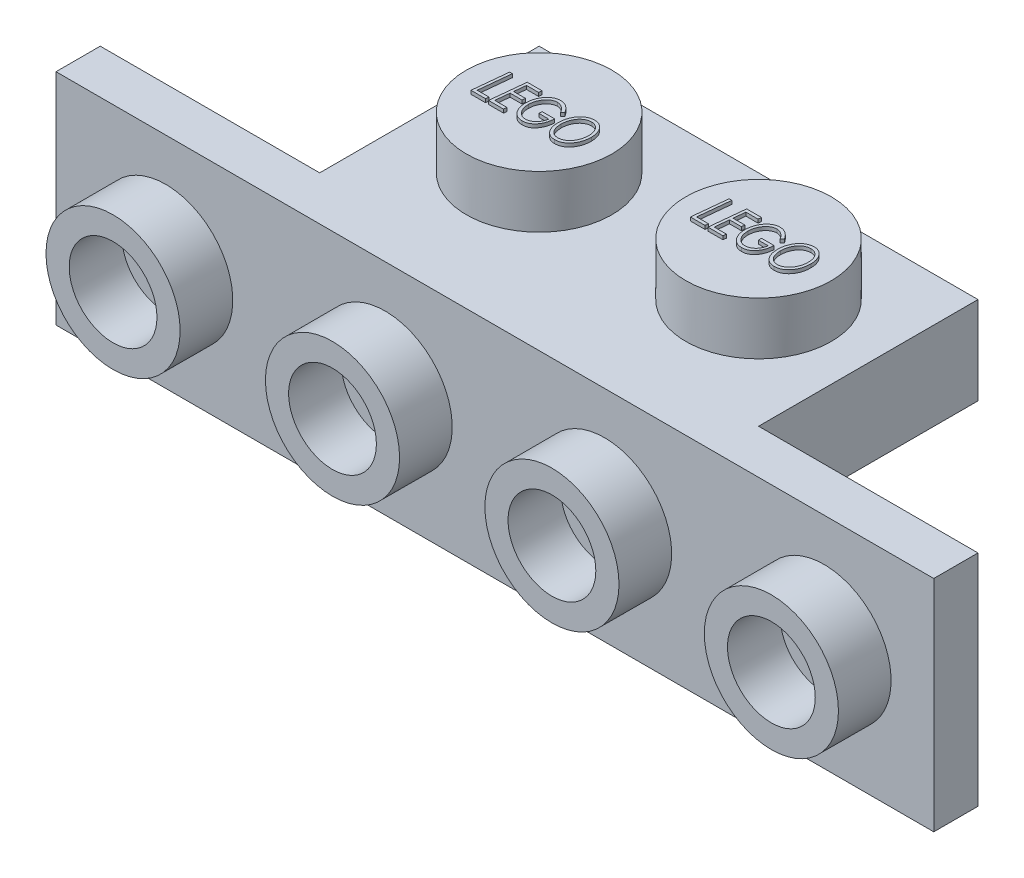
from build123d import *

# Parameters (mm, degrees)
SKETCH2_W           = 15.875
SKETCH2_H           = 7.9375
BOSS_EXTRUDE3_DEPTH = 3.175
SKETCH3_R           = 2.630752939
BOSS_EXTRUDE4_DEPTH = 1.905
LPATTERN1_COUNT     = 2
LPATTERN1_PITCH     = 7.9375
SHELL1_T            = -1.524
BOSS_EXTRUDE5_DEPTH = 0.127
LPATTERN2_COUNT     = 2
LPATTERN2_PITCH     = 7.9375
SKETCH5_R           = 1.4986
SKETCH5_R_2         = 0.635
BOSS_EXTRUDE6_DEPTH = 1.651
SKETCH6_W           = 31.75
SKETCH6_H           = 7.9375
BOSS_EXTRUDE7_DEPTH = 1.6002
SKETCH7_R           = 2.4257
SKETCH7_R_2         = 1.5875
BOSS_EXTRUDE8_DEPTH = 1.905
LPATTERN3_COUNT     = 4
LPATTERN3_PITCH     = 7.9375


with BuildPart() as part:
    # Sketch2 → Boss-Extrude3 (new body)
    with BuildSketch(Plane(origin=(0, 0, 0), x_dir=(1, 0, 0), z_dir=(0, 1, 0))):
        with Locations((-9.795613381, 4.754641089)):
            Rectangle(SKETCH2_W, SKETCH2_H)
    extrude(amount=BOSS_EXTRUDE3_DEPTH)

    # Sketch3 → Boss-Extrude4 (add)
    with BuildSketch(Plane(origin=(0, 3.175, 0), x_dir=(1, 0, 0), z_dir=(0, 1, 0))):
        with Locations((-13.764363381, 4.754641089)):
            Circle(SKETCH3_R)
    boss_extrude4 = extrude(amount=BOSS_EXTRUDE4_DEPTH)

    # LPattern1: Boss-Extrude4 ×2
    with Locations(*[(i * LPATTERN1_PITCH, 0, 0) for i in range(1, LPATTERN1_COUNT)]):
        add(boss_extrude4)

    # Shell1
    shell1_openings = [part.faces().sort_by_distance(p)[0] for p in [
        (-9.795613381, 0, -4.754641089),
    ]]
    offset(amount=SHELL1_T, openings=shell1_openings, kind=Kind.INTERSECTION)

    # Sketch4 → Boss-Extrude5 (add)
    with BuildSketch(Plane(origin=(0, 5.08, 0), x_dir=(1, 0, 0), z_dir=(0, 1, 0))):
        Polygon((-15.421955913, 5.34660841), (-15.323500384, 5.34660841), (-15.441290849, 4.190582769), (-15.01414141, 4.190582769), (-15.02533532, 4.07660841), (-15.551449102, 4.07660841), align=None)
        Polygon((-14.248885, 5.34660841), (-14.262877387, 5.232634051), (-14.699694294, 5.232634051), (-14.742943493, 4.809300718), (-14.314013205, 4.809300718), (-14.326733557, 4.695326359), (-14.754646217, 4.695326359), (-14.806036442, 4.190582769), (-14.362859359, 4.190582769), (-14.374307676, 4.07660841), (-14.916449102, 4.07660841), (-14.786701506, 5.34660841), align=None)
        with BuildLine():
            Line((-13.157987564, 5.079226599), (-13.23685375, 5.004685333))
            add(Edge.make_bspline(
                [(-13.23685375, 5.004685333), (-13.243036349, 5.014919943), (-13.255215537, 5.03508124), (-13.274843903, 5.0639219), (-13.295404966, 5.090766309), (-13.316668722, 5.115943823), (-13.338681843, 5.139287343), (-13.361588027, 5.160749301), (-13.385450265, 5.180091456), (-13.409701872, 5.197942406), (-13.434658284, 5.213660022), (-13.459747782, 5.227481566), (-13.485177989, 5.238904833), (-13.510565197, 5.248734726), (-13.536282118, 5.256136896), (-13.562187777, 5.261089256), (-13.588089761, 5.264689825), (-13.605477312, 5.265029123), (-13.614139407, 5.265198154)],
                knots=[0, 0, 0, 0, 3.5867e-05, 7.0655e-05, 0.000104594, 0.000137266, 0.00016948, 0.0002008, 0.000231355, 0.000261581, 0.000291084, 0.000319773, 0.000347439, 0.000374655, 0.000401388, 0.000427582, 0.000453742, 0.000479711, 0.000479711, 0.000479711, 0.000479711], degree=3))
            add(Edge.make_bspline(
                [(-13.614139407, 5.265198154), (-13.623817018, 5.264942089), (-13.643246281, 5.264428001), (-13.672242613, 5.260605848), (-13.70083591, 5.253771652), (-13.729278127, 5.244988175), (-13.757272205, 5.233098144), (-13.785048709, 5.218900423), (-13.812373825, 5.20184576), (-13.839460855, 5.182752056), (-13.865426178, 5.16117013), (-13.890266569, 5.13792049), (-13.91359838, 5.112994152), (-13.935710508, 5.086452282), (-13.955872189, 5.057845897), (-13.975112242, 5.027830316), (-13.992587445, 4.995991744), (-14.008566347, 4.962671117), (-14.023015409, 4.928317995), (-14.035508966, 4.893155428), (-14.045942052, 4.857372561), (-14.054589121, 4.820944025), (-14.06149942, 4.783854091), (-14.066312673, 4.746142046), (-14.069143076, 4.707836031), (-14.069568079, 4.682101861), (-14.069782435, 4.669122433)],
                knots=[0, 0, 0, 0, 2.903e-05, 5.8283e-05, 8.7534e-05, 0.000117144, 0.000147477, 0.000178653, 0.000210636, 0.000244026, 0.000278, 0.000311837, 0.000346034, 0.000380367, 0.000415383, 0.000450953, 0.000487277, 0.000524259, 0.000561774, 0.000599029, 0.000636142, 0.000673537, 0.00071131, 0.000749271, 0.000787535, 0.000826472, 0.000826472, 0.000826472, 0.000826472], degree=3))
            add(Edge.make_bspline(
                [(-14.069782435, 4.669122433), (-14.069477418, 4.651721569), (-14.068877636, 4.617504752), (-14.063037479, 4.567164063), (-14.053971473, 4.518756671), (-14.041310983, 4.472223428), (-14.024646127, 4.42784351), (-14.004569657, 4.385349364), (-13.980409537, 4.345047805), (-13.953305264, 4.306998763), (-13.923509762, 4.272231716), (-13.891611692, 4.241833165), (-13.858241554, 4.215836332), (-13.822960448, 4.194859762), (-13.786317389, 4.177985595), (-13.747701019, 4.166780357), (-13.707804487, 4.159194772), (-13.680575585, 4.158413751), (-13.666801666, 4.158018667)],
                knots=[0, 0, 0, 0, 5.2184e-05, 0.000102614, 0.000151811, 0.000199829, 0.000247083, 0.000293853, 0.000340625, 0.000387856, 0.000433855, 0.000477763, 0.000519845, 0.000560465, 0.000600659, 0.0006405, 0.000680822, 0.0007221, 0.0007221, 0.0007221, 0.0007221], degree=3))
            add(Edge.make_bspline(
                [(-13.666801666, 4.158018667), (-13.650119891, 4.158598006), (-13.616764989, 4.159756384), (-13.567583001, 4.170959003), (-13.519199429, 4.187625511), (-13.472815147, 4.211693168), (-13.428975753, 4.24107788), (-13.3888146, 4.275137052), (-13.353443755, 4.314132031), (-13.322014522, 4.35741319), (-13.295472287, 4.406100752), (-13.27204085, 4.459501556), (-13.253441597, 4.518549092), (-13.244174766, 4.559989791), (-13.23939782, 4.581352)],
                knots=[0, 0, 0, 0, 4.9973e-05, 9.9921e-05, 0.000150611, 0.000203177, 0.000256167, 0.000308679, 0.000360721, 0.000413748, 0.000468753, 0.000526746, 0.000588456, 0.000654111, 0.000654111, 0.000654111, 0.000654111], degree=3))
            Line((-13.23939782, 4.581352), (-13.597602948, 4.581352))
            Line((-13.597602948, 4.581352), (-13.597602948, 4.695326359))
            Line((-13.597602948, 4.695326359), (-13.141705512, 4.695326359))
            add(Edge.make_bspline(
                [(-13.141705512, 4.695326359), (-13.143220249, 4.671630935), (-13.14618471, 4.625257073), (-13.156473523, 4.557663764), (-13.169882793, 4.493369383), (-13.188032162, 4.432650411), (-13.210191974, 4.37537214), (-13.236456597, 4.321477624), (-13.266757599, 4.270933421), (-13.300959259, 4.224225256), (-13.338414001, 4.182195788), (-13.37822362, 4.145176879), (-13.420442551, 4.113917018), (-13.464913787, 4.088167818), (-13.511934995, 4.06856876), (-13.561029266, 4.05415967), (-13.612484302, 4.045619356), (-13.647519936, 4.044574047), (-13.665275224, 4.044044308)],
                knots=[0, 0, 0, 0, 7.12e-05, 0.000139344, 0.00020491, 0.000268096, 0.00032923, 0.000388964, 0.000447735, 0.000505793, 0.000562373, 0.000616384, 0.000668589, 0.000719646, 0.000770156, 0.000821037, 0.000872858, 0.000926102, 0.000926102, 0.000926102, 0.000926102], degree=3))
            add(Edge.make_bspline(
                [(-13.665275224, 4.044044308), (-13.683458795, 4.044552296), (-13.719178417, 4.045550182), (-13.771372456, 4.054296421), (-13.821069071, 4.067841152), (-13.868065514, 4.087506656), (-13.912556407, 4.112374207), (-13.953984263, 4.143464588), (-13.993154071, 4.179412869), (-14.029026836, 4.220871562), (-14.061293356, 4.26652386), (-14.090007965, 4.315160597), (-14.113916063, 4.366865748), (-14.133555901, 4.421262957), (-14.148827293, 4.478548833), (-14.159713516, 4.538607223), (-14.166095756, 4.601566492), (-14.167008525, 4.644430286), (-14.167474743, 4.666323955)],
                knots=[0, 0, 0, 0, 5.4515e-05, 0.000107089, 0.00015832, 0.000208732, 0.000259537, 0.000310826, 0.000363759, 0.000418756, 0.000474947, 0.000531277, 0.000587959, 0.00064558, 0.000704576, 0.000765604, 0.000828511, 0.000894188, 0.000894188, 0.000894188, 0.000894188], degree=3))
            add(Edge.make_bspline(
                [(-14.167474743, 4.666323955), (-14.167185589, 4.682101713), (-14.16661133, 4.713436248), (-14.163381594, 4.759994442), (-14.157432775, 4.805749539), (-14.149274332, 4.850644315), (-14.139160769, 4.894945835), (-14.126422318, 4.938327925), (-14.111352878, 4.98094547), (-14.094155797, 5.022494256), (-14.074869439, 5.062577802), (-14.053847868, 5.100800933), (-14.03078607, 5.136684011), (-14.006484206, 5.170754132), (-13.979939226, 5.202226268), (-13.951836475, 5.231556391), (-13.922318071, 5.259016319), (-13.890824475, 5.283795413), (-13.858123028, 5.306042524), (-13.824881044, 5.325834039), (-13.790743443, 5.34211596), (-13.756112763, 5.355771227), (-13.720646944, 5.366079712), (-13.684726153, 5.373904452), (-13.648081628, 5.378221983), (-13.623478046, 5.378854133), (-13.611086522, 5.379172513)],
                knots=[0, 0, 0, 0, 4.7337e-05, 9.4011e-05, 0.000139924, 0.000185684, 0.000230857, 0.000276183, 0.000321242, 0.000366409, 0.000411014, 0.000454628, 0.000497184, 0.000538913, 0.000580086, 0.000620572, 0.000660721, 0.00070093, 0.000740658, 0.000779316, 0.000816866, 0.000854, 0.000890868, 0.000927543, 0.000964179, 0.001001354, 0.001001354, 0.001001354, 0.001001354], degree=3))
            add(Edge.make_bspline(
                [(-13.611086522, 5.379172513), (-13.599885481, 5.378887615), (-13.577690409, 5.378323085), (-13.544759644, 5.375041802), (-13.512580278, 5.369229816), (-13.481226926, 5.36060081), (-13.450309917, 5.350370482), (-13.420236456, 5.337162127), (-13.39072561, 5.322040578), (-13.362124517, 5.304229546), (-13.334002379, 5.284471776), (-13.306931369, 5.261858803), (-13.280001622, 5.237508559), (-13.254169985, 5.210414835), (-13.228831131, 5.181124192), (-13.20464202, 5.149192743), (-13.18043895, 5.115396141), (-13.16557029, 5.091442492), (-13.157987564, 5.079226599)],
                knots=[0, 0, 0, 0, 3.3606e-05, 6.6591e-05, 9.9176e-05, 0.000131574, 0.000164077, 0.000196781, 0.000230006, 0.000263473, 0.000297779, 0.000333024, 0.000369219, 0.000406644, 0.000445248, 0.000485345, 0.000526779, 0.000569901, 0.000569901, 0.000569901, 0.000569901], degree=3))
        make_face()
        with BuildLine():
            add(Edge.make_bspline(
                [(-12.369325705, 5.379172513), (-12.353010143, 5.378720522), (-12.32085994, 5.377829863), (-12.273715249, 5.369659659), (-12.22864765, 5.356507424), (-12.185856311, 5.337650018), (-12.145072326, 5.313842859), (-12.10647493, 5.284550539), (-12.070049375, 5.250024202), (-12.036169842, 5.210647693), (-12.00531375, 5.167406166), (-11.978235129, 5.120902684), (-11.955360597, 5.071642915), (-11.936357429, 5.019696609), (-11.921887955, 4.964835989), (-11.911994605, 4.907187182), (-11.905270318, 4.84685662), (-11.904608097, 4.805673345), (-11.904269615, 4.784623234)],
                knots=[0, 0, 0, 0, 4.8912e-05, 9.6383e-05, 0.000143072, 0.00018944, 0.000236302, 0.000284436, 0.000334467, 0.000386593, 0.000440034, 0.000493616, 0.000547793, 0.000602762, 0.000659349, 0.000717739, 0.000778115, 0.000841241, 0.000841241, 0.000841241, 0.000841241], degree=3))
            add(Edge.make_bspline(
                [(-11.904269615, 4.784623234), (-11.904724813, 4.758992871), (-11.905619371, 4.708623908), (-11.913649979, 4.634691374), (-11.926918957, 4.563951657), (-11.945042207, 4.49615546), (-11.969268607, 4.431731122), (-11.997812291, 4.369990143), (-12.032508136, 4.311855249), (-12.071636526, 4.257287391), (-12.11438555, 4.207292778), (-12.160684455, 4.163785264), (-12.209491268, 4.12681072), (-12.260952984, 4.096525947), (-12.315022525, 4.072933007), (-12.371712054, 4.05602052), (-12.43112154, 4.045889546), (-12.47164277, 4.044665448), (-12.49220431, 4.044044308)],
                knots=[0, 0, 0, 0, 7.6873e-05, 0.000151071, 0.000222773, 0.000292635, 0.000361299, 0.000429016, 0.000496426, 0.000564063, 0.000630262, 0.000693435, 0.00075429, 0.000813586, 0.000872147, 0.000930825, 0.000990675, 0.00105233, 0.00105233, 0.00105233, 0.00105233], degree=3))
            add(Edge.make_bspline(
                [(-12.49220431, 4.044044308), (-12.509616292, 4.04451494), (-12.543682005, 4.04543571), (-12.593480052, 4.053188575), (-12.640452828, 4.066244037), (-12.684989099, 4.084066344), (-12.726670432, 4.107489433), (-12.765818741, 4.135865921), (-12.802122503, 4.169487075), (-12.83534682, 4.207966726), (-12.865201071, 4.250535984), (-12.891189794, 4.296615807), (-12.91347966, 4.345682347), (-12.931507817, 4.398084844), (-12.945433182, 4.453595942), (-12.955221104, 4.512216375), (-12.961524863, 4.573921358), (-12.962237892, 4.616189815), (-12.962602948, 4.637830365)],
                knots=[0, 0, 0, 0, 5.2215e-05, 0.000102157, 0.000150733, 0.000198212, 0.000245705, 0.000293794, 0.000342944, 0.000393802, 0.000446031, 0.000498666, 0.000552293, 0.000607486, 0.000664684, 0.000723782, 0.000785651, 0.000850556, 0.000850556, 0.000850556, 0.000850556], degree=3))
            add(Edge.make_bspline(
                [(-12.962602948, 4.637830365), (-12.962348656, 4.654713021), (-12.961844621, 4.68817633), (-12.958119133, 4.737832996), (-12.952514622, 4.786550271), (-12.943616351, 4.83402181), (-12.933066316, 4.8806248), (-12.919782503, 4.926031082), (-12.904304725, 4.970508016), (-12.88616901, 5.013561667), (-12.866377445, 5.055186009), (-12.843997862, 5.094446642), (-12.820275911, 5.131646309), (-12.79433308, 5.166341896), (-12.767012283, 5.199072462), (-12.737321482, 5.229081319), (-12.705989763, 5.256911788), (-12.672917443, 5.282323432), (-12.638580562, 5.305193307), (-12.602929741, 5.324828759), (-12.566454338, 5.341794401), (-12.528918438, 5.355489869), (-12.490336002, 5.365956739), (-12.450894272, 5.373598515), (-12.410399159, 5.378302894), (-12.383076102, 5.378881385), (-12.369325705, 5.379172513)],
                knots=[0, 0, 0, 0, 5.0643e-05, 0.00010038, 0.000149323, 0.000197677, 0.000245196, 0.000292617, 0.000339526, 0.000386395, 0.000432706, 0.000477705, 0.000521881, 0.000564978, 0.000607585, 0.000649681, 0.000691492, 0.000733218, 0.000774708, 0.000815134, 0.000855202, 0.000895282, 0.000934843, 0.000975008, 0.001015717, 0.001056959, 0.001056959, 0.001056959, 0.001056959], degree=3))
        make_face()
        with BuildLine():
            add(Edge.make_bspline(
                [(-12.37059774, 5.265198154), (-12.382313596, 5.264974538), (-12.405384953, 5.264534185), (-12.43952799, 5.260405022), (-12.472806234, 5.254641281), (-12.50500305, 5.2453884), (-12.53641925, 5.23449868), (-12.566541003, 5.220073421), (-12.596086752, 5.204049224), (-12.624325369, 5.185085614), (-12.651275466, 5.163901314), (-12.677105719, 5.1407675), (-12.701242778, 5.115240955), (-12.723914887, 5.087622005), (-12.745319033, 5.058107871), (-12.765258418, 5.02643651), (-12.783453767, 4.992497975), (-12.800435903, 4.956872571), (-12.815618513, 4.919838387), (-12.828923446, 4.882001808), (-12.839728639, 4.843441788), (-12.848995625, 4.804516904), (-12.856130352, 4.764939705), (-12.861169544, 4.724771762), (-12.864339072, 4.683929196), (-12.8647191, 4.656492627), (-12.864910641, 4.642664099)],
                knots=[0, 0, 0, 0, 3.5131e-05, 6.9182e-05, 0.000103064, 0.000136333, 0.000169567, 0.000202688, 0.000236393, 0.000270332, 0.000304582, 0.000339169, 0.000374259, 0.000409863, 0.000446299, 0.000483568, 0.000522044, 0.000561759, 0.000601917, 0.000642065, 0.000682008, 0.000721995, 0.000762067, 0.000802584, 0.000843403, 0.000884884, 0.000884884, 0.000884884, 0.000884884], degree=3))
            add(Edge.make_bspline(
                [(-12.864910641, 4.642664099), (-12.864307988, 4.619656102), (-12.863131603, 4.574744224), (-12.854429419, 4.509171597), (-12.839695903, 4.447271889), (-12.822395219, 4.398577377), (-12.806018379, 4.361918699), (-12.792619836, 4.336186177), (-12.777779937, 4.312362342), (-12.762246178, 4.289966829), (-12.745390246, 4.269317365), (-12.727389498, 4.250238819), (-12.708171153, 4.232904881), (-12.688073445, 4.216982903), (-12.666766853, 4.20305699), (-12.644505145, 4.191085763), (-12.621414016, 4.180768501), (-12.597334266, 4.172401088), (-12.572284701, 4.166087649), (-12.546442494, 4.161495703), (-12.519659259, 4.158635539), (-12.50145487, 4.158226513), (-12.49220431, 4.158018667)],
                knots=[0, 0, 0, 0, 6.9012e-05, 0.000134712, 0.000198022, 0.000259579, 0.000289414, 0.000318432, 0.000346532, 0.000373564, 0.000400145, 0.00042642, 0.000452175, 0.000477724, 0.000503267, 0.000528424, 0.00055348, 0.000579065, 0.000604796, 0.000630896, 0.000657755, 0.000685504, 0.000685504, 0.000685504, 0.000685504], degree=3))
            add(Edge.make_bspline(
                [(-12.49220431, 4.158018667), (-12.481164543, 4.158226379), (-12.45926255, 4.158638462), (-12.426815915, 4.163069526), (-12.394912776, 4.169171543), (-12.363753517, 4.178557501), (-12.333054523, 4.1901992), (-12.30315314, 4.204836709), (-12.27362727, 4.221656145), (-12.245054493, 4.241259996), (-12.217396148, 4.263059149), (-12.191102552, 4.2869402), (-12.166751424, 4.31313992), (-12.143343282, 4.340857537), (-12.121926482, 4.370957713), (-12.101553921, 4.402800133), (-12.083509498, 4.437043875), (-12.066362584, 4.472756352), (-12.051268705, 4.510002211), (-12.037904005, 4.548157353), (-12.027111895, 4.587233797), (-12.017881689, 4.626845971), (-12.010718503, 4.667266057), (-12.005706916, 4.708370092), (-12.002526277, 4.750312827), (-12.002151397, 4.778511748), (-12.001961923, 4.79276426)],
                knots=[0, 0, 0, 0, 3.3097e-05, 6.5662e-05, 9.8093e-05, 0.000130454, 0.000163149, 0.000196488, 0.000230221, 0.000265008, 0.000300331, 0.000335806, 0.000371442, 0.000407566, 0.000444563, 0.000482183, 0.000520883, 0.000560598, 0.000600991, 0.00064138, 0.000681813, 0.000722543, 0.000763366, 0.000804893, 0.000846727, 0.000889479, 0.000889479, 0.000889479, 0.000889479], degree=3))
            add(Edge.make_bspline(
                [(-12.001961923, 4.79276426), (-12.002383429, 4.811264), (-12.003207157, 4.847417056), (-12.008729979, 4.900202516), (-12.018384404, 4.949996074), (-12.031884335, 4.996843587), (-12.049147304, 5.040781654), (-12.070413266, 5.081809748), (-12.095511146, 5.119934561), (-12.115257706, 5.142857206), (-12.125094935, 5.15427668)],
                knots=[0, 0, 0, 0, 5.5498e-05, 0.000108457, 0.000158999, 0.000207469, 0.000254523, 0.000300379, 0.00034589, 0.00039107, 0.00039107, 0.00039107, 0.00039107], degree=3))
            add(Edge.make_bspline(
                [(-12.125094935, 5.15427668), (-12.133669324, 5.163096064), (-12.150521626, 5.180429887), (-12.178137379, 5.203115094), (-12.206989058, 5.222389045), (-12.237249627, 5.237947562), (-12.268734009, 5.250365639), (-12.301624315, 5.258916547), (-12.335745739, 5.264150728), (-12.358876291, 5.264845883), (-12.37059774, 5.265198154)],
                knots=[0, 0, 0, 0, 3.6878e-05, 7.2482e-05, 0.000106986, 0.00014078, 0.00017437, 0.000208309, 0.000242526, 0.000277679, 0.000277679, 0.000277679, 0.000277679], degree=3))
        make_face(mode=Mode.SUBTRACT)
    boss_extrude5 = extrude(amount=BOSS_EXTRUDE5_DEPTH)

    # LPattern2: Boss-Extrude5 ×2
    with Locations(*[(i * LPATTERN2_PITCH, 0, 0) for i in range(1, LPATTERN2_COUNT)]):
        add(boss_extrude5)

    # Sketch5 → Boss-Extrude6 (add)
    with BuildSketch(Plane.XZ):
        with Locations((-9.795613381, -4.754641089)):
            Circle(SKETCH5_R)
        with Locations((-9.795613381, -4.754641089)):
            Circle(SKETCH5_R_2, mode=Mode.SUBTRACT)
    extrude(amount=-BOSS_EXTRUDE6_DEPTH)

    # Sketch6 → Boss-Extrude7 (add)
    with BuildSketch(Plane.XY.offset(-0.785891089)):
        with Locations((-9.795613381, -0.79375)):
            Rectangle(SKETCH6_W, SKETCH6_H)
    extrude(amount=BOSS_EXTRUDE7_DEPTH)

    # Sketch7 → Boss-Extrude8 (add)
    with BuildSketch(Plane.XY.offset(0.814308911)):
        with Locations((-21.701863381, -0.79375)):
            Circle(SKETCH7_R)
        with Locations((-21.701863381, -0.79375)):
            Circle(SKETCH7_R_2, mode=Mode.SUBTRACT)
    boss_extrude8 = extrude(amount=BOSS_EXTRUDE8_DEPTH)

    # LPattern3: Boss-Extrude8 ×4
    with Locations(*[(i * LPATTERN3_PITCH, 0, 0) for i in range(1, LPATTERN3_COUNT)]):
        add(boss_extrude8)


solid = part.part
